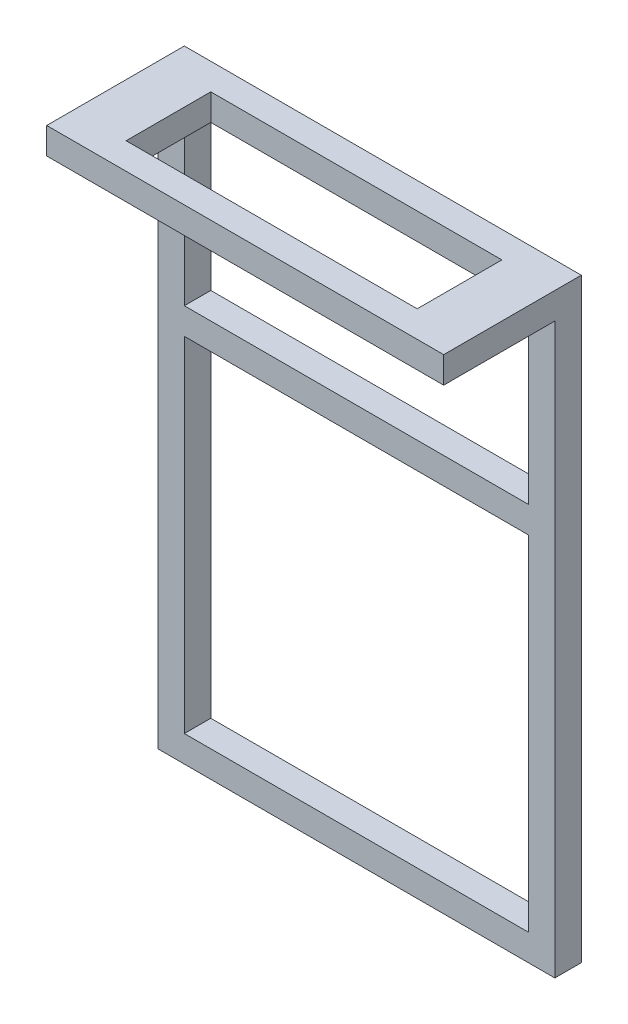
from build123d import *

# Parameters (mm, degrees)
SKETCH1_W           = 30
SKETCH1_H           = 10.4
BOSS_EXTRUDE1_DEPTH = 2
SKETCH2_W           = 22
SKETCH2_H           = 6.4
CUT_EXTRUDE1_DEPTH  = 3
SKETCH4_W           = 30
SKETCH4_H           = 2
BOSS_EXTRUDE2_DEPTH = 45
SKETCH5_W           = 26
SKETCH5_H           = 26
CUT_EXTRUDE3_DEPTH  = 11.4
SKETCH6_W           = 26
SKETCH6_H           = 13
CUT_EXTRUDE4_DEPTH  = 11.4


with BuildPart() as part:
    # Sketch1 → Boss-Extrude1 (new body)
    with BuildSketch(Plane(origin=(0, 0, 0), x_dir=(1, 0, 0), z_dir=(0, 1, 0))):
        with Locations((15, -5.2)):
            Rectangle(SKETCH1_W, SKETCH1_H)
    extrude(amount=BOSS_EXTRUDE1_DEPTH)

    # Sketch2 → Cut-Extrude1 (cut, through all)
    with BuildSketch(Plane(origin=(0, 2, 0), x_dir=(1, 0, 0), z_dir=(0, 1, 0))):
        with Locations((15, -5.2)):
            Rectangle(SKETCH2_W, SKETCH2_H)
    extrude(amount=-CUT_EXTRUDE1_DEPTH, mode=Mode.SUBTRACT)

    # Sketch4 → Boss-Extrude2 (add)
    with BuildSketch(Plane(origin=(0, 2, 0), x_dir=(1, 0, 0), z_dir=(0, 1, 0))):
        with Locations((15, -1)):
            Rectangle(SKETCH4_W, SKETCH4_H)
    extrude(amount=-BOSS_EXTRUDE2_DEPTH)

    # Sketch5 → Cut-Extrude3 (cut, through all)
    with BuildSketch(Plane(origin=(0, 0, 0), x_dir=(-1, 0, 0), z_dir=(0, 0, -1))):
        with Locations((-15, -28)):
            Rectangle(SKETCH5_W, SKETCH5_H)
    extrude(amount=-CUT_EXTRUDE3_DEPTH, mode=Mode.SUBTRACT)

    # Sketch6 → Cut-Extrude4 (cut, through all)
    with BuildSketch(Plane(origin=(0, 0, 0), x_dir=(-1, 0, 0), z_dir=(0, 0, -1))):
        with Locations((-15, -6.5)):
            Rectangle(SKETCH6_W, SKETCH6_H)
    extrude(amount=-CUT_EXTRUDE4_DEPTH, mode=Mode.SUBTRACT)


solid = part.part
